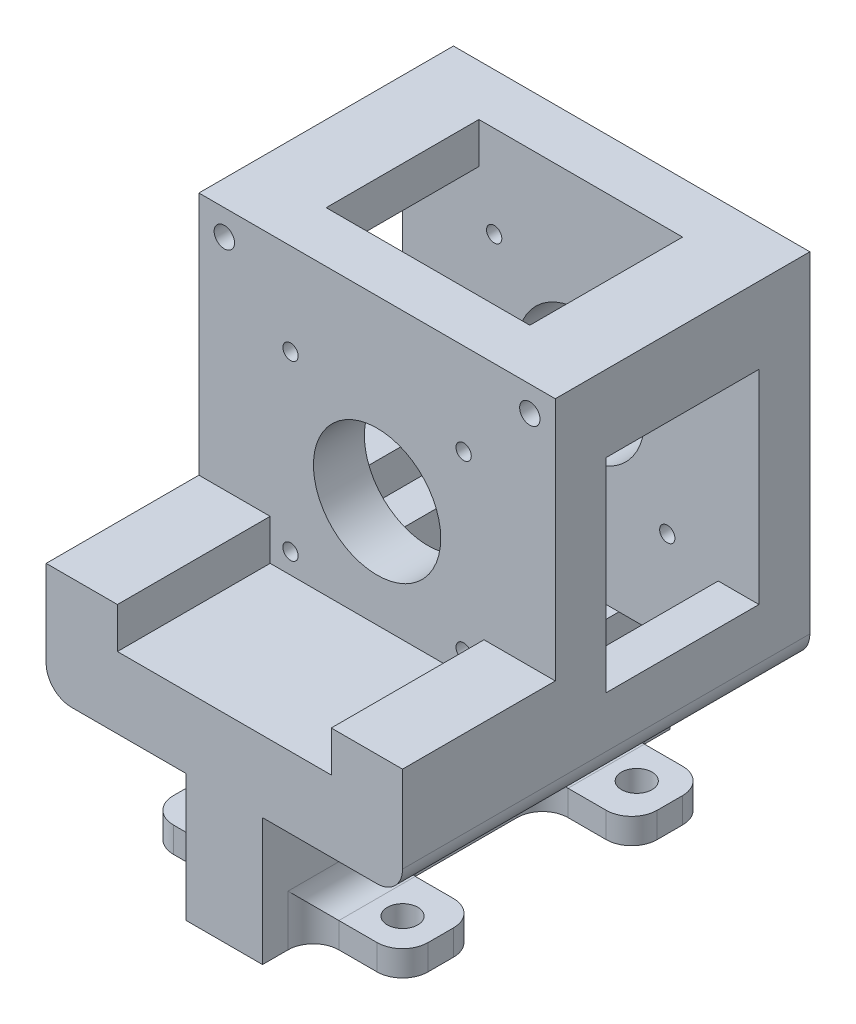
from build123d import *

# Parameters (mm, degrees)
SKETCH1_W                 = 70
SKETCH1_H                 = 70
SKETCH1_R                 = 12.5
SKETCH1_R_2               = 1.5
BOSS_EXTRUDE1_DEPTH       = 10
BOSS_EXTRUDE2_DEPTH       = 30
BOSS_EXTRUDE3_DEPTH       = 30
CIRPATTERN1_COUNT         = 4
SKETCH4_R                 = 2
CUT_EXTRUDE1_DEPTH        = 50
SKETCH6_W                 = 15
SKETCH6_H                 = 80
BOSS_EXTRUDE4_DEPTH       = 25
SKETCH7_W                 = 50
SKETCH7_H                 = 15
BOSS_EXTRUDE5_DEPTH       = 5
F_6_0MM_DOWEL_HOLE1_D     = 6
F_6_0MM_DOWEL_HOLE1_DEPTH = 5
FILLET1_R                 = 5
FILLET2_R                 = 5
FILLET3_R                 = 5


with BuildPart() as part:
    # Sketch1 → Boss-Extrude1 (new body)
    with BuildSketch(Plane.XY):
        Rectangle(SKETCH1_W, SKETCH1_H)
        Circle(SKETCH1_R, mode=Mode.SUBTRACT)
        with Locations((17, 17)):
            Circle(SKETCH1_R_2, mode=Mode.SUBTRACT)
        with Locations((-17, 17)):
            Circle(SKETCH1_R_2, mode=Mode.SUBTRACT)
        with Locations((17, -17)):
            Circle(SKETCH1_R_2, mode=Mode.SUBTRACT)
        with Locations((-17, -17)):
            Circle(SKETCH1_R_2, mode=Mode.SUBTRACT)
    boss_extrude1 = extrude(amount=BOSS_EXTRUDE1_DEPTH)

    # Sketch2 → Boss-Extrude2 (add)
    with BuildSketch(Plane.XY.offset(10)):
        Polygon((-21, -13), (-21, -21), (21, -21), (21, -13), (35, -13), (35, -35), (-35, -35), (-35, -13), align=None)
    extrude(amount=BOSS_EXTRUDE2_DEPTH)

    # Sketch3 → Boss-Extrude3 (add)
    with BuildSketch(Plane(origin=(0, 0, 0), x_dir=(-1, 0, 0), z_dir=(0, 0, -1))):
        Polygon((27, 20), (35, 20), (35, 35), (20, 35), (20, 27), (27, 27), align=None)
    boss_extrude3 = extrude(amount=BOSS_EXTRUDE3_DEPTH)

    # CirPattern1: Boss-Extrude3 ×4 about axis
    cirpattern1_axis = Axis((0, 0, 0), (0, 0, 1))
    for i in range(1, CIRPATTERN1_COUNT):
        add(boss_extrude3.rotate(cirpattern1_axis, i * 360 / CIRPATTERN1_COUNT))

    # Mirror1: Boss-Extrude1 across plane
    add(boss_extrude1.mirror(Plane(origin=(0, 0, -15), x_dir=(1, 0, 0), z_dir=(0, 0, -1))))

    # Sketch4 → Cut-Extrude1 (cut)
    with BuildSketch(Plane(origin=(0, 0, -40), x_dir=(-1, 0, 0), z_dir=(0, 0, -1))):
        with Locations((30, 30)):
            Circle(SKETCH4_R)
    cut_extrude1 = extrude(amount=-CUT_EXTRUDE1_DEPTH, mode=Mode.SUBTRACT)

    # Mirror2: Cut-Extrude1 across plane
    add(cut_extrude1.mirror(Plane(origin=(0, 0, 0), x_dir=(0, 0, 1), z_dir=(1, 0, 0))), mode=Mode.SUBTRACT)

    # Sketch6 → Boss-Extrude4 (add)
    with BuildSketch(Plane.XZ.offset(35)):
        Rectangle(SKETCH6_W, SKETCH6_H)
    extrude(amount=BOSS_EXTRUDE4_DEPTH)

    # Sketch7 → Boss-Extrude5 (add)
    with BuildSketch(Plane.XZ.offset(60)):
        with Locations((0, 22.5)):
            Rectangle(SKETCH7_W, SKETCH7_H)
        with Locations((0, -22.5)):
            Rectangle(SKETCH7_W, SKETCH7_H)
    extrude(amount=-BOSS_EXTRUDE5_DEPTH)

    # Ø6.0mm Dowel Hole1
    with Locations(Plane(origin=(-18, -60, 23), x_dir=(0, 0, -1), z_dir=(0, -1, 0))):
        with Locations((0, 0), (0, 36), (46, 0), (46, 36)):
            Hole(F_6_0MM_DOWEL_HOLE1_D / 2, depth=F_6_0MM_DOWEL_HOLE1_DEPTH)

    # Fillet1
    fillet1_edges = [part.edges().sort_by_distance(p)[0] for p in [
        (25, -57.5, 15),
        (-25, -57.5, 30),
        (25, -57.5, 30),
        (7.5, -57.5, 15),
        (-7.5, -57.5, 15),
        (-25, -57.5, 15),
        (7.5, -57.5, 30),
        (-7.5, -57.5, 30),
        (25, -57.5, -30),
        (-25, -57.5, -15),
        (25, -57.5, -15),
        (7.5, -57.5, -30),
        (-7.5, -57.5, -30),
        (-25, -57.5, -30),
        (7.5, -57.5, -15),
        (-7.5, -57.5, -15),
    ]]
    fillet(fillet1_edges, radius=FILLET1_R)

    # Fillet2
    fillet2_edges = [part.edges().sort_by_distance(p)[0] for p in [
        (-7.5, -55, 22.5),
        (-7.5, -55, -22.5),
        (7.5, -55, -22.5),
        (7.5, -55, 22.5),
    ]]
    fillet(fillet2_edges, radius=FILLET2_R)

    # Fillet3
    fillet3_edges = [part.edges().sort_by_distance(p)[0] for p in [
        (-35, -35, 0),
        (35, -35, 0),
    ]]
    fillet(fillet3_edges, radius=FILLET3_R)


solid = part.part
